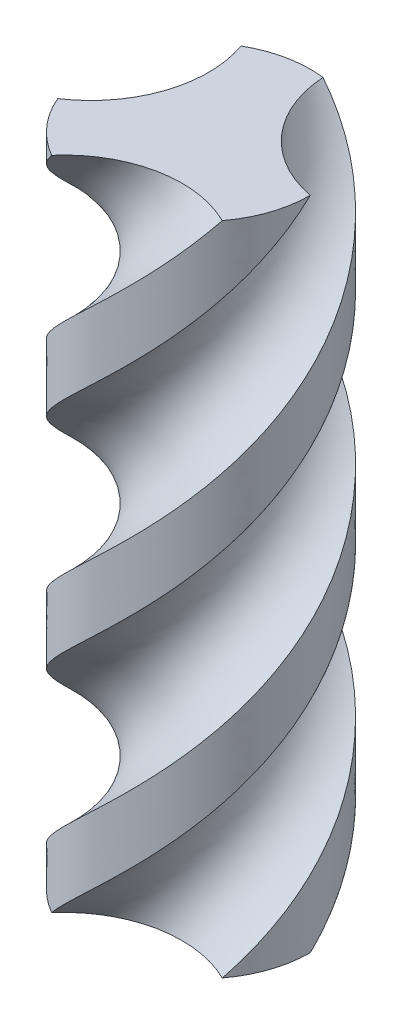
from build123d import *

# Parameters (mm, degrees)
SWEEP3_PITCH       = 300
SWEEP3_HEIGHT      = 300
SWEEP3_RADIUS      = 50
SWEEP3_START_ANGLE = 90
CIRPATTERN1_COUNT  = 3


with BuildPart() as part:
    # Sweep3: sweep along a helix
    with BuildLine() as sweep3_path:
        add(Helix(SWEEP3_PITCH, SWEEP3_HEIGHT, SWEEP3_RADIUS, center=(0, 0, 0), direction=(0, -1, 0), mode=Mode.PRIVATE).rotate(Axis((0, 0, 0), (0, -1, 0)), SWEEP3_START_ANGLE))
    # Sketch2 → Sweep3 (sweep)
    with BuildSketch(Plane(origin=(0, 0, 0), x_dir=(1, 0, 0), z_dir=(0, 1, 0))):
        with BuildLine():
            Line((-25, 43.301270189), (0, 0))
            Line((0, 0), (49.999999981, -0.001371126))
            ThreePointArc((49.999999981, -0.001371126), (19.580501459, 17.28752043), (6.194105143, 49.614847188))
            ThreePointArc((6.194105143, 49.614847188), (-9.918706265, 49.006318634), (-25, 43.301270189))
        make_face()
    sweep3 = sweep(path=sweep3_path.line, is_frenet=True)

    # CirPattern1: Sweep3 ×3 about axis
    cirpattern1_axis = Axis((0, 0, 0), (0, 1, 0))
    for i in range(1, CIRPATTERN1_COUNT):
        add(sweep3.rotate(cirpattern1_axis, i * 360 / CIRPATTERN1_COUNT))


solid = part.part
